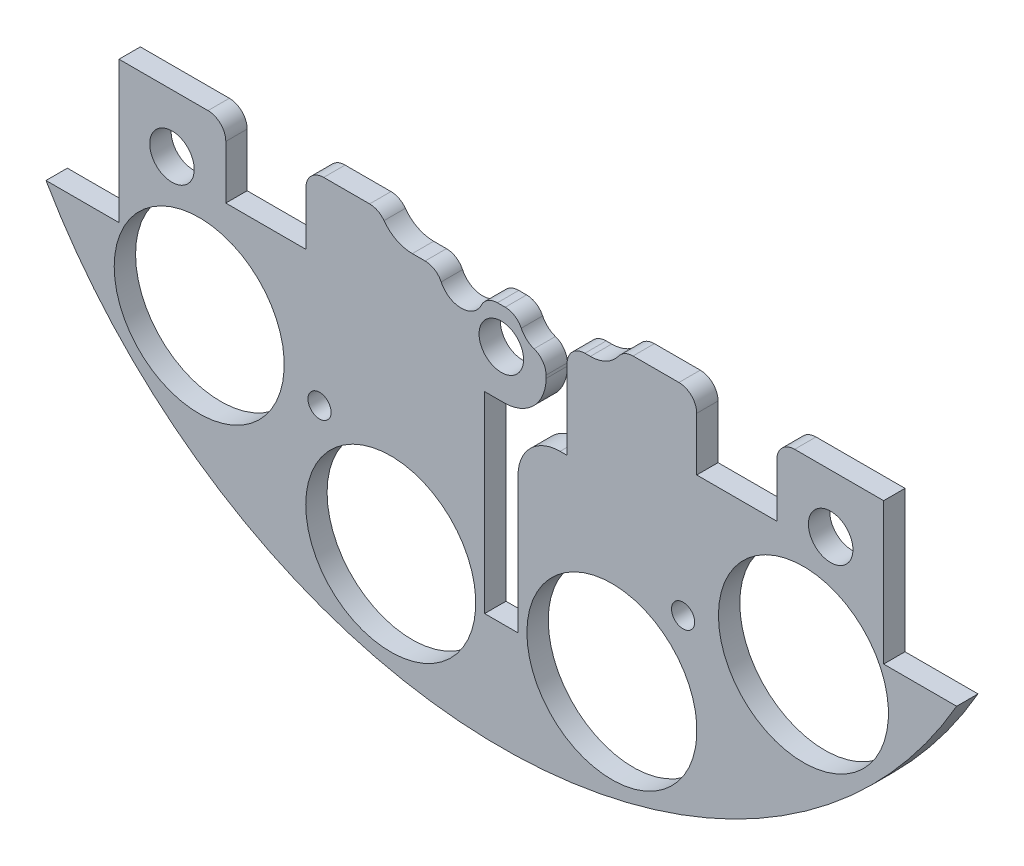
from build123d import *

# Parameters (mm, degrees)
SKETCH1_R                 = 1.651
BOSS_EXTRUDE2_DEPTH       = 3.048
SKETCH2_R                 = 1.143
CUT_EXTRUDE1_DEPTH        = 4.048
SKETCH3_R                 = 12.1285
CUT_EXTRUDE2_DEPTH        = 4.048
SKETCH4_W                 = 28.562713242
SKETCH4_H                 = 11.677503754
BOSS_EXTRUDE3_DEPTH       = 3.048
SKETCH5_W                 = 216.7214489
SKETCH5_H                 = 130.569220634
CUT_EXTRUDE4_DEPTH        = 4.048
SKETCH6_W                 = 4.7625
SKETCH6_H                 = 27.432
CUT_EXTRUDE5_DEPTH        = 4.048
SKETCH10_W                = 11.43
SKETCH10_H                = 10.16
CUT_EXTRUDE9_DEPTH        = 4.048
FILLET1_R                 = 6
FILLET2_R                 = 6
SKETCH66_R                = 1.651
CUT_EXTRUDE65_DEPTH       = 97.79
SKETCH120_R               = 3.175
CUT_EXTRUDE119_DEPTH      = 103.378
CUT_EXTRUDE119_DEPTH_BACK = 48.768
CUT_EXTRUDE12_DEPTH       = 10
FILLET3_R                 = 2.54


with BuildPart() as part:
    # Sketch1 → Boss-Extrude2 (new body)
    with BuildSketch(Plane.XY):
        with BuildLine():
            Line((-64.964441474, 37.338), (-54.550441474, 37.338))
            Line((-54.550441474, 37.338), (-54.550441474, -37.338))
            Line((-54.550441474, -37.338), (-64.964441474, -37.338))
            ThreePointArc((-64.964441474, -37.338), (0, -74.93), (64.964441474, -37.338))
            Line((64.964441474, -37.338), (54.550441474, -37.338))
            Line((54.550441474, -37.338), (54.550441474, 37.338))
            Line((54.550441474, 37.338), (64.964441474, 37.338))
            ThreePointArc((64.964441474, 37.338), (0, 74.93), (-64.964441474, 37.338))
        make_face()
        with Locations((-46.482, 11.049)):
            Circle(SKETCH1_R, mode=Mode.SUBTRACT)
        with Locations((-21.083270032, 10.795)):
            Circle(SKETCH1_R, mode=Mode.SUBTRACT)
        with Locations((-21.083270032, -10.795)):
            Circle(SKETCH1_R, mode=Mode.SUBTRACT)
        with Locations((-46.482, -11.049)):
            Circle(SKETCH1_R, mode=Mode.SUBTRACT)
        with Locations((46.482, -11.049)):
            Circle(SKETCH1_R, mode=Mode.SUBTRACT)
        with Locations((21.083270032, -10.795)):
            Circle(SKETCH1_R, mode=Mode.SUBTRACT)
        with Locations((21.083270032, 10.795)):
            Circle(SKETCH1_R, mode=Mode.SUBTRACT)
        with Locations((46.482, 11.049)):
            Circle(SKETCH1_R, mode=Mode.SUBTRACT)
    extrude(amount=BOSS_EXTRUDE2_DEPTH)

    # Sketch2 → Cut-Extrude1 (cut, through all)
    with BuildSketch(Plane.XY.offset(3.048)):
        with Locations((-6.731, 62.23)):
            Circle(SKETCH2_R)
        with Locations((6.731, 62.23)):
            Circle(SKETCH2_R)
    extrude(amount=-CUT_EXTRUDE1_DEPTH, mode=Mode.SUBTRACT)

    # Sketch3 → Cut-Extrude2 (cut, through all)
    with BuildSketch(Plane(origin=(0, 0, 0), x_dir=(-1, 0, 0), z_dir=(0, 0, -1))):
        with Locations((-15.777608989, -58.882838371)):
            Circle(SKETCH3_R)
        with Locations((15.777608989, -58.882838371)):
            Circle(SKETCH3_R)
        with Locations((-43.105229381, -43.105229381)):
            Circle(SKETCH3_R)
        with Locations((19.05, 32.995567884)):
            Circle(SKETCH3_R)
        with Locations((-43.105229381, 43.105229381)):
            Circle(SKETCH3_R)
        with Locations((43.105229381, 43.105229381)):
            Circle(SKETCH3_R)
        with Locations((-19.05, 32.995567884)):
            Circle(SKETCH3_R)
        with Locations((43.105229381, -43.105229381)):
            Circle(SKETCH3_R)
    extrude(amount=-CUT_EXTRUDE2_DEPTH, mode=Mode.SUBTRACT)

    # Sketch4 → Boss-Extrude3 (add)
    with BuildSketch(Plane(origin=(0, 0, 0), x_dir=(-1, 0, 0), z_dir=(0, 0, -1))):
        with Locations((-1.488809975, 62.152540216)):
            Rectangle(SKETCH4_W, SKETCH4_H)
    extrude(amount=-BOSS_EXTRUDE3_DEPTH)

    # Sketch5 → Cut-Extrude4 (cut, through all)
    with BuildSketch(Plane(origin=(0, 0, 0), x_dir=(-1, 0, 0), z_dir=(0, 0, -1))):
        with Locations((23.316688373, 48.139610317)):
            Rectangle(SKETCH5_W, SKETCH5_H)
    extrude(amount=-CUT_EXTRUDE4_DEPTH, mode=Mode.SUBTRACT)

    # Sketch6 → Cut-Extrude5 (cut, through all)
    with BuildSketch(Plane(origin=(0, 0, 0), x_dir=(-1, 0, 0), z_dir=(0, 0, -1))):
        with Locations((0, -45.847)):
            Rectangle(SKETCH6_W, SKETCH6_H)
        Polygon((-2.38125, -34.131), (-2.38125, -32.131), (-6.38125, -32.131), (-6.38125, -17.145), (-9.38125, -17.145), (-9.38125, -34.131), align=None)
    extrude(amount=-CUT_EXTRUDE5_DEPTH, mode=Mode.SUBTRACT)

    # Sketch10 → Cut-Extrude9 (cut, through all)
    with BuildSketch(Plane(origin=(0, 0, 0), x_dir=(-1, 0, 0), z_dir=(0, 0, -1))):
        with Locations((-33.595441474, -22.225)):
            Rectangle(SKETCH10_W, SKETCH10_H)
        with Locations((33.595441474, -22.225)):
            Rectangle(SKETCH10_W, SKETCH10_H)
    extrude(amount=-CUT_EXTRUDE9_DEPTH, mode=Mode.SUBTRACT)

    # Fillet1
    fillet1_edges = [part.edges().sort_by_distance(p)[0] for p in [
        (6.38125, -32.131, 1.524),
    ]]
    fillet(fillet1_edges, radius=FILLET1_R)

    # Fillet2
    fillet2_edges = [part.edges().sort_by_distance(p)[0] for p in [
        (2.38125, -34.131, 1.524),
    ]]
    fillet(fillet2_edges, radius=FILLET2_R)

    # Sketch66 → Cut-Extrude65 (cut)
    with BuildSketch(Plane(origin=(30.092005081, 4.08352975, -16.1925), x_dir=(-1, 0, 0), z_dir=(0, 0, -1))):
        with Locations((4.154396091, -49.728759131)):
            Circle(SKETCH66_R)
        with Locations((56.02961407, -49.728759131)):
            Circle(SKETCH66_R)
    extrude(amount=-CUT_EXTRUDE65_DEPTH, mode=Mode.SUBTRACT)

    # Sketch120 → Cut-Extrude119 (cut, two sides)
    with BuildSketch(Plane(origin=(30.092005081, 4.08352975, 19.939), x_dir=(-1, 0, 0), z_dir=(0, 0, -1))) as cut_extrude119_sk:
        with Locations((77.082005081, -29.48352975)):
            Circle(SKETCH120_R)
        with Locations((30.092005081, -29.48352975)):
            Circle(SKETCH120_R)
        with Locations((-16.897994919, -29.48352975)):
            Circle(SKETCH120_R)
    extrude(amount=CUT_EXTRUDE119_DEPTH, mode=Mode.SUBTRACT)
    extrude(cut_extrude119_sk.sketch, amount=-CUT_EXTRUDE119_DEPTH_BACK, mode=Mode.SUBTRACT)

    # Sketch13 → Cut-Extrude12 (cut)
    with BuildSketch(Plane(origin=(0, 0, 0), x_dir=(-1, 0, 0), z_dir=(0, 0, -1))):
        with BuildLine():
            Line((-12.7, -20.24), (-8.888991966, -20.24))
            ThreePointArc((-8.888991966, -20.24), (-5.715, -23.495), (-2.541008034, -20.24))
            Line((-2.541008034, -20.24), (2.541008034, -20.24))
            ThreePointArc((2.541008034, -20.24), (5.715, -23.495), (8.888991966, -20.24))
            Line((8.888991966, -20.24), (12.7, -20.24))
            ThreePointArc((12.7, -20.24), (16.235533906, -11.704466094), (7.7, -15.24))
            Line((7.7, -15.24), (-1.0625, -15.24))
            ThreePointArc((-1.0625, -15.24), (-4.012347567, -10.679640913), (-9.38125, -11.500227489))
            ThreePointArc((-9.38125, -11.500227489), (-17.374337523, -13.465015853), (-12.7, -20.24))
        make_face()
    extrude(amount=-CUT_EXTRUDE12_DEPTH, mode=Mode.SUBTRACT)

    # Fillet3
    fillet3_edges = [part.edges().sort_by_distance(p)[0] for p in [
        (39.310441474, -17.145, 1.524),
        (27.880441474, -17.145, 1.524),
        (-27.880441474, -17.145, 1.524),
        (-39.310441474, -17.145, 1.524),
        (6.38125, -23.424309253, 1.524),
        (9.38125, -20.24, 1.524),
        (17.322875188, -17.145, 1.524),
        (-17.322875188, -17.145, 1.524),
        (-8.888991966, -20.24, 1.524),
        (-2.541008034, -20.24, 1.524),
        (2.541008034, -20.24, 1.524),
    ]]
    fillet(fillet3_edges, radius=FILLET3_R)


solid = part.part
